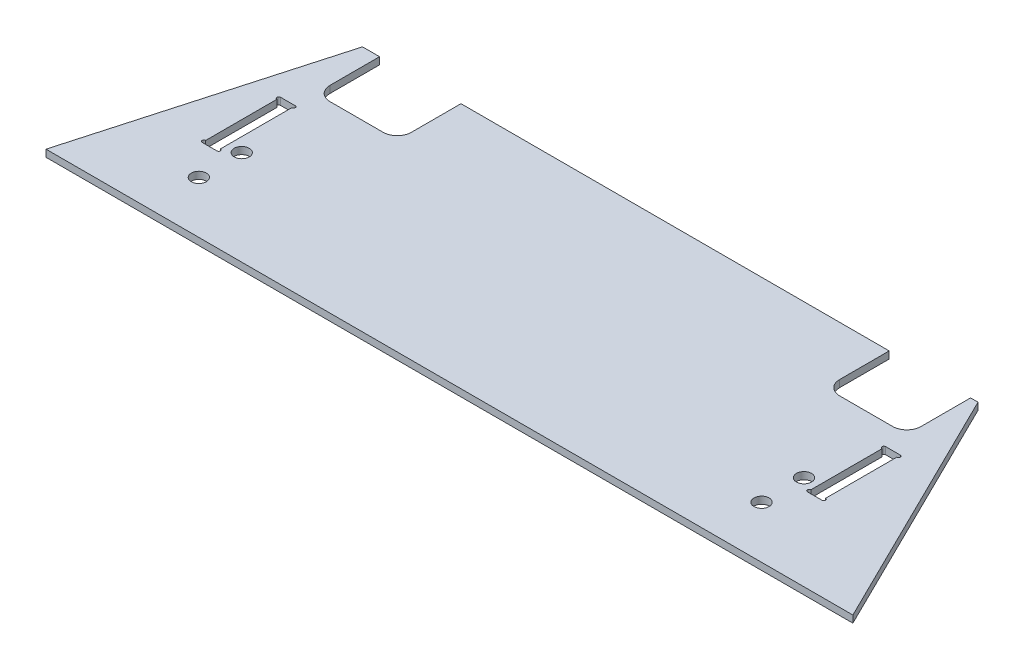
from build123d import *

# Parameters (mm, degrees)
SKETCH1_W               = 361.95
SKETCH1_H               = 110.744
BOSS_EXTRUDE1_DEPTH     = 3.175
CUT_EXTRUDE1_DEPTH      = 4.175
SKETCH3_W               = 36.5125
SKETCH3_H               = 28.575
CUT_EXTRUDE2_DEPTH      = 4.175
FILLET1_R               = 6.35
F_1_4_CLEARANCE_HOLE1_D = 6.7564
SKETCH7_W               = 6.604
SKETCH7_H               = 35.117637185
CUT_EXTRUDE4_DEPTH      = 4.175
SKETCH8_R               = 0.79375
CUT_EXTRUDE5_DEPTH      = 4.175


with BuildPart() as part:
    # Sketch1 → Boss-Extrude1 (new body)
    with BuildSketch(Plane(origin=(0, 0, 0), x_dir=(1, 0, 0), z_dir=(0, 1, 0))):
        with Locations((180.975, 55.372)):
            Rectangle(SKETCH1_W, SKETCH1_H)
    extrude(amount=BOSS_EXTRUDE1_DEPTH)

    # Sketch2 → Cut-Extrude1 (cut, through all)
    with BuildSketch(Plane(origin=(0, 3.175, 0), x_dir=(1, 0, 0), z_dir=(0, 1, 0))):
        Polygon((0, 0), (31.233038214, 110.744), (0, 110.744), align=None)
        Polygon((361.95, 0), (307.33710294, 110.744), (361.95, 110.744), align=None)
    extrude(amount=-CUT_EXTRUDE1_DEPTH, mode=Mode.SUBTRACT)

    # Sketch3 → Cut-Extrude2 (cut, through all)
    with BuildSketch(Plane(origin=(0, 3.175, 0), x_dir=(1, 0, 0), z_dir=(0, 1, 0))):
        with Locations((57.15, 96.4565)):
            Rectangle(SKETCH3_W, SKETCH3_H)
        with Locations((285.75, 96.4565)):
            Rectangle(SKETCH3_W, SKETCH3_H)
    extrude(amount=-CUT_EXTRUDE2_DEPTH, mode=Mode.SUBTRACT)

    # Fillet1
    fillet1_edges = [part.edges().sort_by_distance(p)[0] for p in [
        (75.40625, 1.5875, -82.169),
        (38.89375, 1.5875, -82.169),
        (304.00625, 1.5875, -82.169),
        (267.49375, 1.5875, -82.169),
    ]]
    fillet(fillet1_edges, radius=FILLET1_R)

    # 1/4 Clearance Hole1 (through all)
    with Locations(Plane(origin=(0, 3.175, 0), x_dir=(1, 0, 0), z_dir=(0, 1, 0))):
        with Locations((297.65625, 42.364421689), (297.65625, 23.314421689), (45.24375, 23.314421689), (45.24375, 42.559885057)):
            Hole(F_1_4_CLEARANCE_HOLE1_D / 2)

    # Sketch7 → Cut-Extrude4 (cut, through all)
    with BuildSketch(Plane(origin=(0, 3.175, 0), x_dir=(1, 0, 0), z_dir=(0, 1, 0))):
        with Locations((307.18125, 55.212181407)):
            Rectangle(SKETCH7_W, SKETCH7_H)
        with Locations((35.71875, 55.212181407)):
            Rectangle(SKETCH7_W, SKETCH7_H)
    extrude(amount=-CUT_EXTRUDE4_DEPTH, mode=Mode.SUBTRACT)

    # Sketch8 → Cut-Extrude5 (cut, through all)
    with BuildSketch(Plane(origin=(0, 3.175, 0), x_dir=(1, 0, 0), z_dir=(0, 1, 0))):
        with Locations((39.02075, 38.447112815)):
            Circle(SKETCH8_R)
        with Locations((39.02075, 71.97725)):
            Circle(SKETCH8_R)
        with Locations((32.41675, 71.97725)):
            Circle(SKETCH8_R)
        with Locations((32.41675, 38.447112815)):
            Circle(SKETCH8_R)
        with Locations((303.87925, 71.97725)):
            Circle(SKETCH8_R)
        with Locations((310.48325, 71.97725)):
            Circle(SKETCH8_R)
        with Locations((310.48325, 38.447112815)):
            Circle(SKETCH8_R)
        with Locations((303.87925, 38.447112815)):
            Circle(SKETCH8_R)
    extrude(amount=-CUT_EXTRUDE5_DEPTH, mode=Mode.SUBTRACT)


solid = part.part
